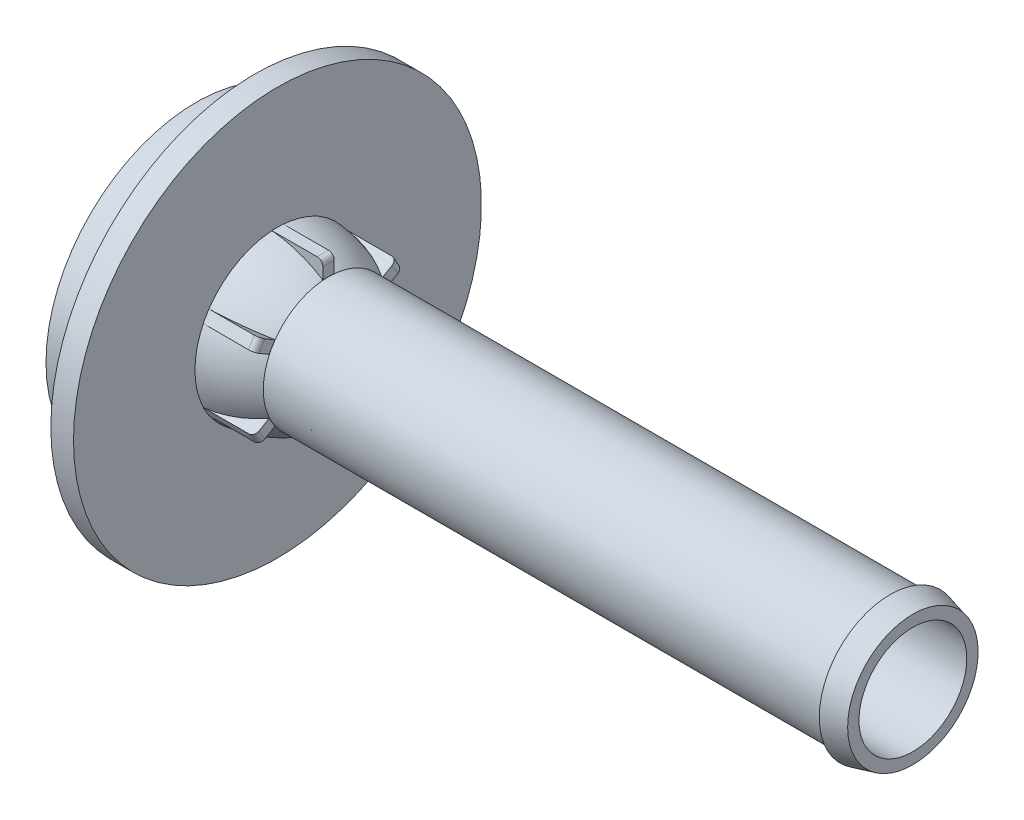
from build123d import *
from build123d.topology import SkipClean

# Parameters (mm, degrees)
SKETCH1_R           = 2.921
BOSS_EXTRUDE1_DEPTH = 26.162
SKETCH4_R           = 9.1313
BOSS_EXTRUDE3_DEPTH = 1.016
SKETCH6_R           = 6.731
BOSS_EXTRUDE4_DEPTH = 2.6162
SKETCH7_R           = 6.223
CUT_EXTRUDE1_DEPTH  = 2.6162
SKETCH8_R           = 4.1275
BOSS_EXTRUDE5_DEPTH = 4.191
SKETCH9_R           = 3.1115
CUT_EXTRUDE2_DEPTH  = 5.207
SKETCH10_R          = 2.413
CUT_EXTRUDE3_DEPTH  = 37.047472926
BOSS_EXTRUDE7_DEPTH = 0.254
FILLET1_R           = 0.254
CIRPATTERN5_COUNT   = 6
SKETCH13_R          = 2.413
SKETCH13_R_2        = 1.397
BOSS_EXTRUDE8_DEPTH = 3.429
CUT_EXTRUDE4_DEPTH  = 3.429


with BuildPart() as part:
    # Sketch1 → Boss-Extrude1 (new body)
    with BuildSketch(Plane(origin=(0, 0, 0), x_dir=(0, 0, -1), z_dir=(1, 0, 0))):
        Circle(SKETCH1_R)
    extrude(amount=BOSS_EXTRUDE1_DEPTH)

    # Sketch3 → Revolve2 (revolve)
    with BuildSketch(Plane.XY, mode=Mode.PRIVATE) as revolve2_sk:
        with BuildLine():
            Line((0, 2.921), (0, 2.304776559))
            ThreePointArc((0, 2.304776559), (-1.082934793, 2.900950296), (-2.286, 3.185212498))
            Line((-2.286, 3.185212498), (-2.286, 3.695344539))
            ThreePointArc((-2.286, 3.695344539), (-1.096344298, 3.44590803), (0, 2.921))
        make_face()
    revolve(revolve2_sk.sketch.rotate(Axis((0, 0, 0), (1, 0, 0)), 90), axis=Axis((0, 0, 0), (1, 0, 0)))

    # Sketch4 → Boss-Extrude3 (add)
    with BuildSketch(Plane.ZY.offset(2.286)):
        Circle(SKETCH4_R)
    extrude(amount=BOSS_EXTRUDE3_DEPTH)

    # Sketch6 → Boss-Extrude4 (add)
    with BuildSketch(Plane.ZY.offset(3.302)):
        Circle(SKETCH6_R)
    extrude(amount=BOSS_EXTRUDE4_DEPTH)

    # Sketch7 → Cut-Extrude1 (cut)
    with BuildSketch(Plane.ZY.offset(5.9182)):
        Circle(SKETCH7_R)
    extrude(amount=-CUT_EXTRUDE1_DEPTH, mode=Mode.SUBTRACT)

    # Sketch8 → Boss-Extrude5 (add)
    with BuildSketch(Plane.ZY.offset(3.302)):
        Circle(SKETCH8_R)
    extrude(amount=BOSS_EXTRUDE5_DEPTH)

    # Sketch9 → Cut-Extrude2 (cut)
    with BuildSketch(Plane.ZY.offset(7.493)):
        Circle(SKETCH9_R)
    extrude(amount=-CUT_EXTRUDE2_DEPTH, mode=Mode.SUBTRACT)

    # Sketch10 → Cut-Extrude3 (cut, through all)
    with BuildSketch(Plane(origin=(26.162, 0, 0), x_dir=(0, 0, -1), z_dir=(1, 0, 0))):
        Circle(SKETCH10_R)
    extrude(amount=-CUT_EXTRUDE3_DEPTH, mode=Mode.SUBTRACT)

    # Sketch13 → Boss-Extrude8 (add)
    with BuildSketch(Plane(origin=(16.6624, 0, 0), x_dir=(0, 0, -1), z_dir=(1, 0, 0))):
        Circle(SKETCH13_R)
        Circle(SKETCH13_R_2, mode=Mode.SUBTRACT)
    extrude(amount=BOSS_EXTRUDE8_DEPTH)

    # Sketch14 → Cut-Extrude4 (cut)
    with SkipClean():  # the faces are left unmerged after this step: merging them gives an invalid solid
        with BuildSketch(Plane(origin=(16.6624, 0, 0), x_dir=(0, 0, -1), z_dir=(1, 0, 0))):
            with BuildLine():
                Line((0.979826718, 2.205109658), (0.466887065, 1.316672119))
                ThreePointArc((0.466887065, 1.316672119), (0.6985, 1.209837489), (0.906827971, 1.062672119))
                Line((0.906827971, 1.062672119), (1.419767623, 1.951109658))
                ThreePointArc((1.419767623, 1.951109658), (1.2065, 2.089719299), (0.979826718, 2.205109658))
            make_face()
            with BuildLine():
                Line((0.979826718, -2.205109658), (0.466887065, -1.316672119))
                ThreePointArc((0.466887065, -1.316672119), (0.6985, -1.209837489), (0.906827971, -1.062672119))
                Line((0.906827971, -1.062672119), (1.419767623, -1.951109658))
                ThreePointArc((1.419767623, -1.951109658), (1.2065, -2.089719299), (0.979826718, -2.205109658))
            make_face()
            with BuildLine():
                Line((-2.399594341, 0.254), (-1.373715036, 0.254))
                ThreePointArc((-1.373715036, 0.254), (-1.397, 0), (-1.373715036, -0.254))
                Line((-1.373715036, -0.254), (-2.399594341, -0.254))
                ThreePointArc((-2.399594341, -0.254), (-2.413, 0), (-2.399594341, 0.254))
            make_face()
        extrude(amount=CUT_EXTRUDE4_DEPTH, mode=Mode.SUBTRACT)

    # Sketch15 → Revolve3 (revolve)
    with SkipClean():  # the faces are left unmerged after this step: merging them gives an invalid solid
        with BuildSketch(Plane.XY, mode=Mode.PRIVATE) as revolve3_sk:
            Polygon((26.162, 2.921), (25.146, 3.175), (25.146, 2.921), align=None)
        revolve(revolve3_sk.sketch.rotate(Axis((-10.435666401, 0, 0), (1, 0, 0)), 90), axis=Axis((-10.435666401, 0, 0), (1, 0, 0)))


with BuildPart() as body_2:
    # Sketch12 → Boss-Extrude7 (new, symmetric)
    with BuildSketch(Plane.XY):
        with BuildLine():
            Line((-2.286, 3.695344539), (0, 3.695344539))
            Line((0, 3.695344539), (0, 2.921))
            ThreePointArc((0, 2.921), (-1.096344298, 3.44590803), (-2.286, 3.695344539))
        make_face()
    extrude(amount=BOSS_EXTRUDE7_DEPTH, both=True)

    # Fillet1
    fillet1_edges = [body_2.edges().sort_by_distance(p)[0] for p in [
        (0, 3.695344539, 0),
    ]]
    fillet(fillet1_edges, radius=FILLET1_R)


with BuildPart() as cirpattern5_1:
    # CirPattern5: pattern copy
    add(body_2.part.rotate(Axis((0, 0, 0), (1, 0, 0)), 1 * 360 / CIRPATTERN5_COUNT))


with BuildPart() as cirpattern5_2:
    # CirPattern5: pattern copy
    add(body_2.part.rotate(Axis((0, 0, 0), (1, 0, 0)), 2 * 360 / CIRPATTERN5_COUNT))


with BuildPart() as cirpattern5_3:
    # CirPattern5: pattern copy
    add(body_2.part.rotate(Axis((0, 0, 0), (1, 0, 0)), 3 * 360 / CIRPATTERN5_COUNT))


with BuildPart() as cirpattern5_4:
    # CirPattern5: pattern copy
    add(body_2.part.rotate(Axis((0, 0, 0), (1, 0, 0)), 4 * 360 / CIRPATTERN5_COUNT))


with BuildPart() as cirpattern5_5:
    # CirPattern5: pattern copy
    add(body_2.part.rotate(Axis((0, 0, 0), (1, 0, 0)), 5 * 360 / CIRPATTERN5_COUNT))


solid = Compound([part.part, body_2.part, cirpattern5_1.part, cirpattern5_2.part, cirpattern5_3.part, cirpattern5_4.part, cirpattern5_5.part])
